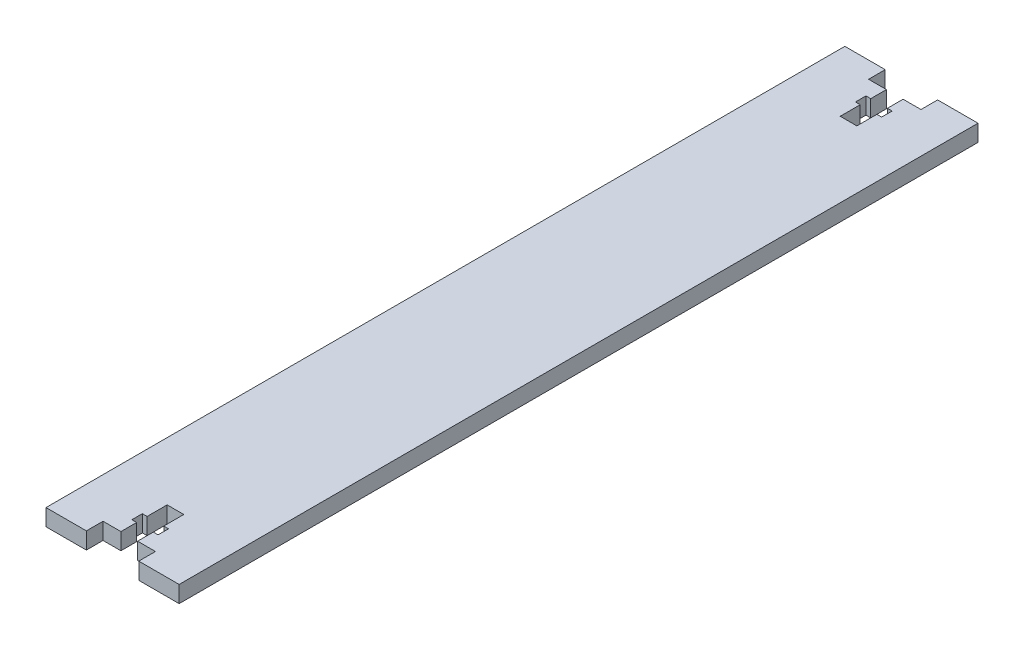
from build123d import *

# Parameters (mm, degrees)
SKETCH1_W           = 25.4
SKETCH1_H           = 152.4
BOSS_EXTRUDE1_DEPTH = 3.18
CUT_EXTRUDE1_DEPTH  = 3.18


with BuildPart() as part:
    # Sketch1 → Boss-Extrude1 (new body)
    with BuildSketch(Plane(origin=(0, 0, 0), x_dir=(1, 0, 0), z_dir=(0, 1, 0))):
        Rectangle(SKETCH1_W, SKETCH1_H)
    extrude(amount=BOSS_EXTRUDE1_DEPTH)

    # Sketch2 → Cut-Extrude1 (cut)
    with BuildSketch(Plane(origin=(0, 3.18, 0), x_dir=(1, 0, 0), z_dir=(0, 1, 0))):
        Polygon((-1.59, 73.02), (-1.59, 70.02), (-2.5, 70.02), (-2.5, 68.02), (-1.59, 68.02), (-1.59, 64.2), (0, 64.2), (1.59, 64.2), (1.59, 68.02), (2.5, 68.02), (2.5, 70.02), (1.59, 70.02), (1.59, 73.02), (5, 73.02), (5, 76.2), (-5, 76.2), (-5, 73.02), align=None)
        Polygon((0, -64.2), (-1.59, -64.2), (-1.59, -68.02), (-2.5, -68.02), (-2.5, -70.02), (-1.59, -70.02), (-1.59, -73.02), (-5, -73.02), (-5, -76.2), (5, -76.2), (5, -73.02), (1.59, -73.02), (1.59, -70.02), (2.5, -70.02), (2.5, -68.02), (1.59, -68.02), (1.59, -64.2), align=None)
    extrude(amount=-CUT_EXTRUDE1_DEPTH, mode=Mode.SUBTRACT)


solid = part.part
